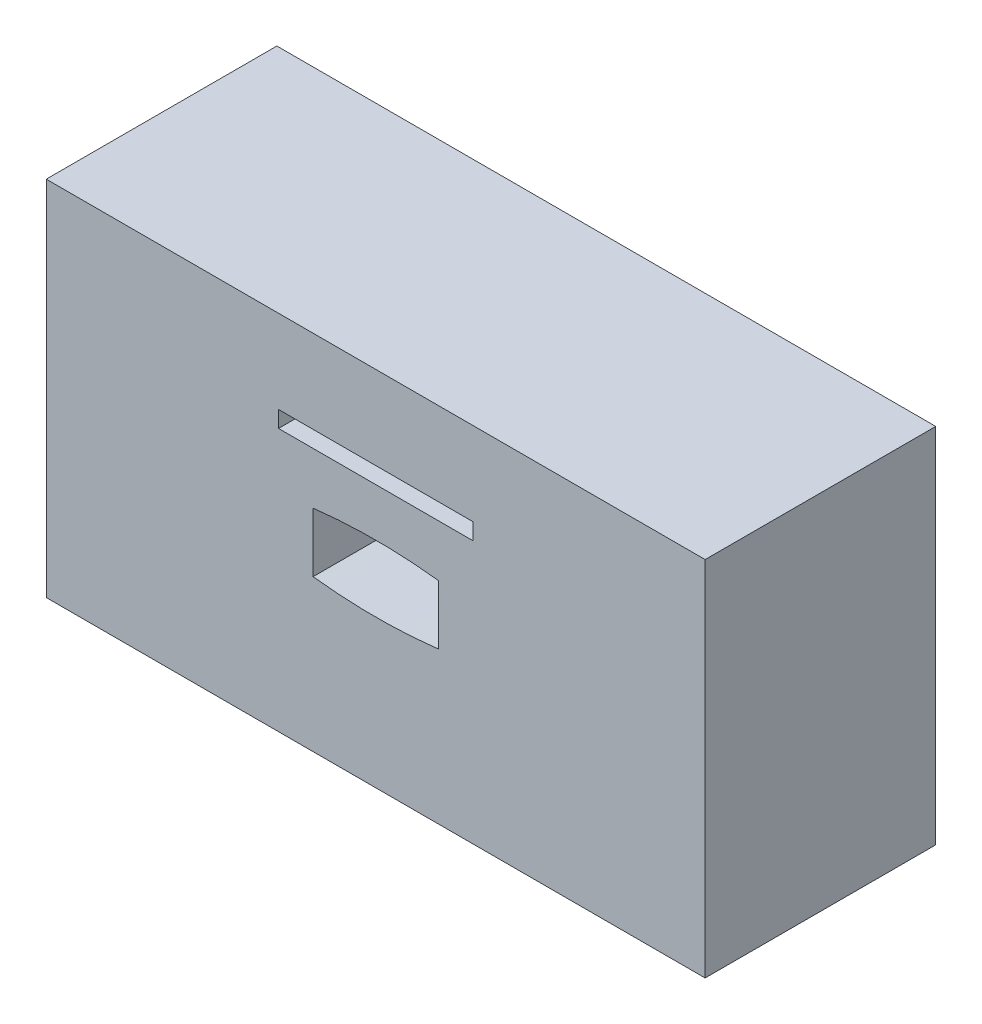
from build123d import *

# Parameters (mm, degrees)
ESQUISSE1_W             = 100
ESQUISSE1_H             = 55
BOSS_EXTRU_1_DEPTH      = 35
ESQUISSE2_W             = 29.5
ESQUISSE2_H             = 2.5
ENL_V_MAT_EXTRU_1_DEPTH = 20


with BuildPart() as part:
    # Esquisse1 → Boss.-Extru.1 (new body)
    with BuildSketch(Plane.XY):
        Rectangle(ESQUISSE1_W, ESQUISSE1_H)
    extrude(amount=BOSS_EXTRU_1_DEPTH)

    # Esquisse2 → Enlèv. mat.-Extru.1 (cut)
    with BuildSketch(Plane.XY.offset(35)):
        with BuildLine():
            Line((-9.5, 4.5), (-9.5, -4.5))
            ThreePointArc((-9.5, -4.5), (0, -5.06418194), (9.5, -4.5))
            Line((9.5, -4.5), (9.5, 4.5))
            ThreePointArc((9.5, 4.5), (0, 5.06418194), (-9.5, 4.5))
        make_face()
        with Locations((0, 13.607565721)):
            Rectangle(ESQUISSE2_W, ESQUISSE2_H)
    extrude(amount=-ENL_V_MAT_EXTRU_1_DEPTH, mode=Mode.SUBTRACT)


solid = part.part
